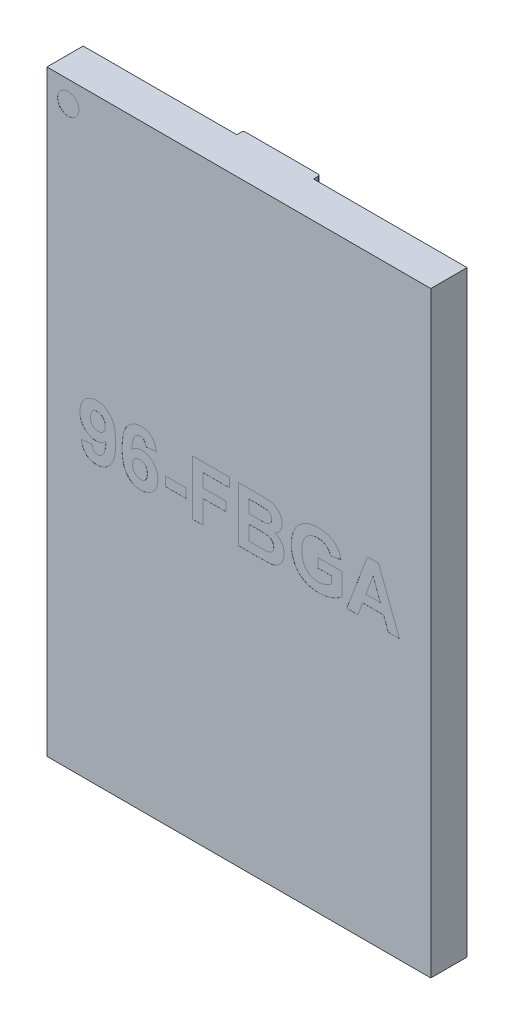
from build123d import *

# Parameters (mm, degrees)
SKETCH1_W           = 9
SKETCH1_H           = 14
BOSS_EXTRUDE1_DEPTH = 0.85
SKETCH2_W           = 1.8
SKETCH2_H           = 14
BOSS_EXTRUDE2_DEPTH = 0.155
SKETCH3_R           = 0.225
BOSS_EXTRUDE3_DEPTH = 0.25
FILLET1_R           = 0.05
FILLET3_R           = 0.225
SKETCH4_R           = 0.25
CUT_EXTRUDE1_DEPTH  = 0.001
SKETCH6_W           = 0.477443858
SKETCH6_H           = 0.214026557
CUT_EXTRUDE2_DEPTH  = 0.001


with BuildPart() as part:
    # Sketch1 → Boss-Extrude1 (new body)
    with BuildSketch(Plane.XY):
        Rectangle(SKETCH1_W, SKETCH1_H)
    extrude(amount=BOSS_EXTRUDE1_DEPTH)

    # Sketch2 → Boss-Extrude2 (add)
    with BuildSketch(Plane(origin=(0, 0, 0), x_dir=(-1, 0, 0), z_dir=(0, 0, -1))):
        Rectangle(SKETCH2_W, SKETCH2_H)
    extrude(amount=BOSS_EXTRUDE2_DEPTH)

    # Sketch3 → Boss-Extrude3 (add)
    with BuildSketch(Plane(origin=(0, 0, 0), x_dir=(-1, 0, 0), z_dir=(0, 0, -1))):
        with Locations((-3.2, 6)):
            Circle(SKETCH3_R)
        with Locations((-2.4, 6)):
            Circle(SKETCH3_R)
        with Locations((-1.6, 6)):
            Circle(SKETCH3_R)
        with Locations((-3.2, 5.2)):
            Circle(SKETCH3_R)
        with Locations((-2.4, 5.2)):
            Circle(SKETCH3_R)
        with Locations((-1.6, 5.2)):
            Circle(SKETCH3_R)
        with Locations((-3.2, 4.4)):
            Circle(SKETCH3_R)
        with Locations((-2.4, 4.4)):
            Circle(SKETCH3_R)
        with Locations((-1.6, 4.4)):
            Circle(SKETCH3_R)
        with Locations((-3.2, 3.6)):
            Circle(SKETCH3_R)
        with Locations((-2.4, 3.6)):
            Circle(SKETCH3_R)
        with Locations((-1.6, 3.6)):
            Circle(SKETCH3_R)
        with Locations((-3.2, 2.8)):
            Circle(SKETCH3_R)
        with Locations((-2.4, 2.8)):
            Circle(SKETCH3_R)
        with Locations((-1.6, 2.8)):
            Circle(SKETCH3_R)
        with Locations((-3.2, 2)):
            Circle(SKETCH3_R)
        with Locations((-2.4, 2)):
            Circle(SKETCH3_R)
        with Locations((-1.6, 2)):
            Circle(SKETCH3_R)
        with Locations((-3.2, 1.2)):
            Circle(SKETCH3_R)
        with Locations((-2.4, 1.2)):
            Circle(SKETCH3_R)
        with Locations((-1.6, 1.2)):
            Circle(SKETCH3_R)
        with Locations((-3.2, 0.4)):
            Circle(SKETCH3_R)
        with Locations((-2.4, 0.4)):
            Circle(SKETCH3_R)
        with Locations((-1.6, 0.4)):
            Circle(SKETCH3_R)
        with Locations((-3.2, -0.4)):
            Circle(SKETCH3_R)
        with Locations((-2.4, -0.4)):
            Circle(SKETCH3_R)
        with Locations((-1.6, -0.4)):
            Circle(SKETCH3_R)
        with Locations((-3.2, -1.2)):
            Circle(SKETCH3_R)
        with Locations((-2.4, -1.2)):
            Circle(SKETCH3_R)
        with Locations((-1.6, -1.2)):
            Circle(SKETCH3_R)
        with Locations((-3.2, -2)):
            Circle(SKETCH3_R)
        with Locations((-2.4, -2)):
            Circle(SKETCH3_R)
        with Locations((-1.6, -2)):
            Circle(SKETCH3_R)
        with Locations((-3.2, -2.8)):
            Circle(SKETCH3_R)
        with Locations((-2.4, -2.8)):
            Circle(SKETCH3_R)
        with Locations((-1.6, -2.8)):
            Circle(SKETCH3_R)
        with Locations((-3.2, -3.6)):
            Circle(SKETCH3_R)
        with Locations((-2.4, -3.6)):
            Circle(SKETCH3_R)
        with Locations((-1.6, -3.6)):
            Circle(SKETCH3_R)
        with Locations((-3.2, -4.4)):
            Circle(SKETCH3_R)
        with Locations((-2.4, -4.4)):
            Circle(SKETCH3_R)
        with Locations((-1.6, -4.4)):
            Circle(SKETCH3_R)
        with Locations((-3.2, -5.2)):
            Circle(SKETCH3_R)
        with Locations((-2.4, -5.2)):
            Circle(SKETCH3_R)
        with Locations((-1.6, -5.2)):
            Circle(SKETCH3_R)
        with Locations((-3.2, -6)):
            Circle(SKETCH3_R)
        with Locations((-2.4, -6)):
            Circle(SKETCH3_R)
        with Locations((-1.6, -6)):
            Circle(SKETCH3_R)
        with Locations((1.6, -6)):
            Circle(SKETCH3_R)
        with Locations((2.4, -6)):
            Circle(SKETCH3_R)
        with Locations((3.2, -6)):
            Circle(SKETCH3_R)
        with Locations((1.6, -5.2)):
            Circle(SKETCH3_R)
        with Locations((2.4, -5.2)):
            Circle(SKETCH3_R)
        with Locations((3.2, -5.2)):
            Circle(SKETCH3_R)
        with Locations((1.6, -4.4)):
            Circle(SKETCH3_R)
        with Locations((2.4, -4.4)):
            Circle(SKETCH3_R)
        with Locations((3.2, -4.4)):
            Circle(SKETCH3_R)
        with Locations((1.6, -3.6)):
            Circle(SKETCH3_R)
        with Locations((2.4, -3.6)):
            Circle(SKETCH3_R)
        with Locations((3.2, -3.6)):
            Circle(SKETCH3_R)
        with Locations((1.6, -2.8)):
            Circle(SKETCH3_R)
        with Locations((2.4, -2.8)):
            Circle(SKETCH3_R)
        with Locations((3.2, -2.8)):
            Circle(SKETCH3_R)
        with Locations((1.6, -2)):
            Circle(SKETCH3_R)
        with Locations((2.4, -2)):
            Circle(SKETCH3_R)
        with Locations((3.2, -2)):
            Circle(SKETCH3_R)
        with Locations((1.6, -1.2)):
            Circle(SKETCH3_R)
        with Locations((2.4, -1.2)):
            Circle(SKETCH3_R)
        with Locations((3.2, -1.2)):
            Circle(SKETCH3_R)
        with Locations((1.6, -0.4)):
            Circle(SKETCH3_R)
        with Locations((2.4, -0.4)):
            Circle(SKETCH3_R)
        with Locations((3.2, -0.4)):
            Circle(SKETCH3_R)
        with Locations((1.6, 0.4)):
            Circle(SKETCH3_R)
        with Locations((2.4, 0.4)):
            Circle(SKETCH3_R)
        with Locations((3.2, 0.4)):
            Circle(SKETCH3_R)
        with Locations((1.6, 1.2)):
            Circle(SKETCH3_R)
        with Locations((2.4, 1.2)):
            Circle(SKETCH3_R)
        with Locations((3.2, 1.2)):
            Circle(SKETCH3_R)
        with Locations((1.6, 2)):
            Circle(SKETCH3_R)
        with Locations((2.4, 2)):
            Circle(SKETCH3_R)
        with Locations((3.2, 2)):
            Circle(SKETCH3_R)
        with Locations((1.6, 2.8)):
            Circle(SKETCH3_R)
        with Locations((2.4, 2.8)):
            Circle(SKETCH3_R)
        with Locations((3.2, 2.8)):
            Circle(SKETCH3_R)
        with Locations((1.6, 3.6)):
            Circle(SKETCH3_R)
        with Locations((2.4, 3.6)):
            Circle(SKETCH3_R)
        with Locations((3.2, 3.6)):
            Circle(SKETCH3_R)
        with Locations((1.6, 4.4)):
            Circle(SKETCH3_R)
        with Locations((2.4, 4.4)):
            Circle(SKETCH3_R)
        with Locations((3.2, 4.4)):
            Circle(SKETCH3_R)
        with Locations((1.6, 5.2)):
            Circle(SKETCH3_R)
        with Locations((2.4, 5.2)):
            Circle(SKETCH3_R)
        with Locations((3.2, 5.2)):
            Circle(SKETCH3_R)
        with Locations((1.6, 6)):
            Circle(SKETCH3_R)
        with Locations((2.4, 6)):
            Circle(SKETCH3_R)
        with Locations((3.2, 6)):
            Circle(SKETCH3_R)
    extrude(amount=BOSS_EXTRUDE3_DEPTH)

    # Fillet1
    fillet1_edges = [part.edges().sort_by_distance(p)[0] for p in [
        (-0.9, 0, -0.155),
        (0.9, 0, -0.155),
    ]]
    fillet(fillet1_edges, radius=FILLET1_R)

    # Fillet3
    fillet3_edges = [part.edges().sort_by_distance(p)[0] for p in [
        (2.625, 0.4, -0.25),
        (1.825, 0.4, -0.25),
        (3.425, -0.4, -0.25),
        (2.625, -0.4, -0.25),
        (1.825, -0.4, -0.25),
        (3.425, -1.2, -0.25),
        (2.625, -1.2, -0.25),
        (1.825, -1.2, -0.25),
        (3.425, -2, -0.25),
        (2.625, -2, -0.25),
        (1.825, -2, -0.25),
        (3.425, -2.8, -0.25),
        (2.625, -2.8, -0.25),
        (1.825, -2.8, -0.25),
        (3.425, -3.6, -0.25),
        (2.625, -3.6, -0.25),
        (1.825, -3.6, -0.25),
        (3.425, -4.4, -0.25),
        (2.625, -4.4, -0.25),
        (1.825, -4.4, -0.25),
        (3.425, -5.2, -0.25),
        (2.625, -5.2, -0.25),
        (1.825, -5.2, -0.25),
        (3.425, -6, -0.25),
        (2.625, -6, -0.25),
        (1.825, -6, -0.25),
        (-2.175, -6, -0.25),
        (-2.975, -6, -0.25),
        (-1.375, -5.2, -0.25),
        (-2.175, -5.2, -0.25),
        (-2.975, -5.2, -0.25),
        (-1.375, -4.4, -0.25),
        (-2.175, -4.4, -0.25),
        (-2.975, -4.4, -0.25),
        (-1.375, -3.6, -0.25),
        (-2.175, -3.6, -0.25),
        (-2.975, -3.6, -0.25),
        (-1.375, -2.8, -0.25),
        (-2.175, -2.8, -0.25),
        (-2.975, -2.8, -0.25),
        (-1.375, -2, -0.25),
        (-2.175, -2, -0.25),
        (-2.975, -2, -0.25),
        (-1.375, -1.2, -0.25),
        (-2.175, -1.2, -0.25),
        (-2.975, -1.2, -0.25),
        (-1.375, -0.4, -0.25),
        (-2.175, -0.4, -0.25),
        (-2.975, -0.4, -0.25),
        (-1.375, 0.4, -0.25),
        (-2.175, 0.4, -0.25),
        (-2.975, 0.4, -0.25),
        (-1.375, 1.2, -0.25),
        (-2.175, 1.2, -0.25),
        (-2.975, 1.2, -0.25),
        (-1.375, 2, -0.25),
        (-2.175, 2, -0.25),
        (-2.975, 2, -0.25),
        (-1.375, 2.8, -0.25),
        (-2.175, 2.8, -0.25),
        (-2.975, 2.8, -0.25),
        (3.425, 6, -0.25),
        (-1.375, 3.6, -0.25),
        (-2.175, 3.6, -0.25),
        (-2.975, 3.6, -0.25),
        (-1.375, 4.4, -0.25),
        (-2.175, 4.4, -0.25),
        (-2.975, 4.4, -0.25),
        (-1.375, 5.2, -0.25),
        (-2.175, 5.2, -0.25),
        (-2.975, 5.2, -0.25),
        (-1.375, 6, -0.25),
        (-1.375, -6, -0.25),
        (-2.175, 6, -0.25),
        (-2.975, 6, -0.25),
        (2.625, 6, -0.25),
        (1.825, 6, -0.25),
        (3.425, 5.2, -0.25),
        (2.625, 5.2, -0.25),
        (1.825, 5.2, -0.25),
        (3.425, 4.4, -0.25),
        (2.625, 4.4, -0.25),
        (1.825, 4.4, -0.25),
        (3.425, 3.6, -0.25),
        (2.625, 3.6, -0.25),
        (1.825, 3.6, -0.25),
        (3.425, 2.8, -0.25),
        (2.625, 2.8, -0.25),
        (1.825, 2.8, -0.25),
        (3.425, 2, -0.25),
        (2.625, 2, -0.25),
        (1.825, 2, -0.25),
        (3.425, 1.2, -0.25),
        (2.625, 1.2, -0.25),
        (1.825, 1.2, -0.25),
        (3.425, 0.4, -0.25),
    ]]
    fillet(fillet3_edges, radius=FILLET3_R)

    # Sketch4 → Cut-Extrude1 (cut)
    with BuildSketch(Plane.XY.offset(0.85)):
        with Locations((-4, 6.5)):
            Circle(SKETCH4_R)
    extrude(amount=-CUT_EXTRUDE1_DEPTH, mode=Mode.SUBTRACT)

    # Sketch6 → Cut-Extrude2 (cut)
    with BuildSketch(Plane.XY.offset(0.85)):
        with BuildLine():
            Line((-3.6941683, -0.158633201), (-3.44721458, -0.131365395))
            add(Edge.make_bspline(
                [(-3.44721458, -0.131365395), (-3.445597513, -0.1431888), (-3.442540925, -0.165537465), (-3.432767179, -0.196204692), (-3.420517221, -0.222528967), (-3.403870298, -0.243712827), (-3.384004018, -0.259882053), (-3.361250879, -0.271549569), (-3.33552008, -0.27827039), (-3.317432242, -0.279104684), (-3.308045869, -0.279537626)],
                knots=[0, 0, 0, 0, 3.5736e-05, 6.7548e-05, 9.6194e-05, 0.000122389, 0.00014762, 0.00017247, 0.000198552, 0.000226687, 0.000226687, 0.000226687, 0.000226687], degree=3))
            add(Edge.make_bspline(
                [(-3.308045869, -0.279537626), (-3.301935615, -0.279396005), (-3.289860004, -0.279116119), (-3.27219485, -0.27517022), (-3.255100449, -0.269638338), (-3.238752999, -0.261541827), (-3.223308781, -0.25112172), (-3.208384828, -0.238613229), (-3.194438911, -0.223615351), (-3.180586529, -0.20640051), (-3.168047894, -0.185252833), (-3.15698184, -0.159602922), (-3.146649755, -0.129457889), (-3.138162522, -0.094442838), (-3.130523208, -0.054859542), (-3.12387741, -0.010581324), (-3.118485576, 0.038418872), (-3.116102459, 0.072703847), (-3.114856032, 0.09063571)],
                knots=[0, 0, 0, 0, 1.8293e-05, 3.6153e-05, 5.4049e-05, 7.2111e-05, 9.0661e-05, 0.000109831, 0.000130392, 0.000152007, 0.000176007, 0.000203876, 0.000235684, 0.000271496, 0.000311856, 0.000356605, 0.000405778, 0.0004597, 0.0004597, 0.0004597, 0.0004597], degree=3))
            add(Edge.make_bspline(
                [(-3.114856032, 0.09063571), (-3.122756333, 0.082156214), (-3.138332922, 0.065437657), (-3.164131316, 0.043503573), (-3.191599956, 0.025062744), (-3.220598314, 0.010198787), (-3.250823868, -0.00194512), (-3.282773553, -0.009933163), (-3.316002507, -0.015413754), (-3.338720564, -0.01588268), (-3.350233796, -0.016120325)],
                knots=[0, 0, 0, 0, 3.4747e-05, 6.8509e-05, 0.000101328, 0.000133773, 0.000166113, 0.000198808, 0.000232389, 0.000266894, 0.000266894, 0.000266894, 0.000266894], degree=3))
            add(Edge.make_bspline(
                [(-3.350233796, -0.016120325), (-3.362854981, -0.015758359), (-3.387774455, -0.015043687), (-3.424434601, -0.009853301), (-3.459756763, -0.001002383), (-3.493797335, 0.011271441), (-3.52638423, 0.027539759), (-3.55793297, 0.046719733), (-3.587766552, 0.069935896), (-3.616320276, 0.095877054), (-3.641998326, 0.125081247), (-3.664930957, 0.156396132), (-3.684336591, 0.189993944), (-3.699988924, 0.225838973), (-3.712094268, 0.263703059), (-3.720895314, 0.303554404), (-3.726037676, 0.345600662), (-3.726738049, 0.374361129), (-3.727095462, 0.389038121)],
                knots=[0, 0, 0, 0, 3.7858e-05, 7.4747e-05, 0.000110809, 0.00014694, 0.000183064, 0.000219904, 0.000257515, 0.000296294, 0.000335474, 0.000373962, 0.00041257, 0.000451618, 0.000491074, 0.000531643, 0.000573888, 0.000617914, 0.000617914, 0.000617914, 0.000617914], degree=3))
            add(Edge.make_bspline(
                [(-3.727095462, 0.389038121), (-3.726770225, 0.404319282), (-3.726132249, 0.434294384), (-3.720535282, 0.477995335), (-3.711987508, 0.519594797), (-3.699224156, 0.558724125), (-3.683342012, 0.595803573), (-3.663601839, 0.630368136), (-3.640657581, 0.662898573), (-3.613846204, 0.692427562), (-3.584701766, 0.719458481), (-3.553261909, 0.742981411), (-3.519709029, 0.762639902), (-3.484340384, 0.778976812), (-3.446890652, 0.791558627), (-3.407599179, 0.800524673), (-3.36642776, 0.806084092), (-3.338332686, 0.806729414), (-3.323994964, 0.80705874)],
                knots=[0, 0, 0, 0, 4.5825e-05, 8.9889e-05, 0.000131966, 0.000173049, 0.000213144, 0.000252772, 0.000292246, 0.000332323, 0.000372192, 0.000411345, 0.00044986, 0.00048865, 0.000528023, 0.000568147, 0.000609404, 0.000652401, 0.000652401, 0.000652401, 0.000652401], degree=3))
            add(Edge.make_bspline(
                [(-3.323994964, 0.80705874), (-3.308364122, 0.806626847), (-3.277713883, 0.805779956), (-3.232792546, 0.798727765), (-3.190169369, 0.786729218), (-3.149420829, 0.770639367), (-3.111134267, 0.749203756), (-3.074811587, 0.723332925), (-3.040938092, 0.692498706), (-3.008920722, 0.657311722), (-2.979790285, 0.61665342), (-2.954988585, 0.569662966), (-2.933892013, 0.516785295), (-2.916863592, 0.457906851), (-2.903557877, 0.39304273), (-2.894374433, 0.322194179), (-2.888229413, 0.245347164), (-2.887718047, 0.192088424), (-2.887452815, 0.164464582)],
                knots=[0, 0, 0, 0, 4.6876e-05, 9.1917e-05, 0.000135981, 0.000179499, 0.000223024, 0.000267282, 0.000312999, 0.00036017, 0.000409781, 0.000462607, 0.000519165, 0.000580297, 0.000646236, 0.000717615, 0.000794502, 0.000877354, 0.000877354, 0.000877354, 0.000877354], degree=3))
            add(Edge.make_bspline(
                [(-2.887452815, 0.164464582), (-2.887836168, 0.136413376), (-2.888576821, 0.082217277), (-2.894552876, 0.003977961), (-2.90401188, -0.068263899), (-2.917919177, -0.134379226), (-2.935371885, -0.194605751), (-2.957317665, -0.248714058), (-2.982877246, -0.296983202), (-3.012798123, -0.338968736), (-3.045691993, -0.37545889), (-3.081046621, -0.407071789), (-3.118912686, -0.433712107), (-3.158961589, -0.455933615), (-3.201792147, -0.472574378), (-3.246811671, -0.48463028), (-3.294141264, -0.492439952), (-3.326536252, -0.493184883), (-3.34303098, -0.493564184)],
                knots=[0, 0, 0, 0, 8.4144e-05, 0.000162569, 0.000235258, 0.000302561, 0.000365072, 0.000423112, 0.000477436, 0.000528542, 0.000577358, 0.000624548, 0.000670511, 0.000715986, 0.000761606, 0.00080797, 0.000855633, 0.000905078, 0.000905078, 0.000905078, 0.000905078], degree=3))
            add(Edge.make_bspline(
                [(-3.34303098, -0.493564184), (-3.354873972, -0.493320459), (-3.378110475, -0.492842261), (-3.412130338, -0.488995122), (-3.444410923, -0.482310039), (-3.474844784, -0.472973975), (-3.503669445, -0.461493508), (-3.530640187, -0.446928618), (-3.555764037, -0.429612222), (-3.579468797, -0.410076536), (-3.600802192, -0.387431419), (-3.620426377, -0.362429543), (-3.638030566, -0.334820732), (-3.65302353, -0.304367675), (-3.666863515, -0.271776844), (-3.678012205, -0.236325889), (-3.687310436, -0.198414841), (-3.691841975, -0.172127932), (-3.6941683, -0.158633201)],
                knots=[0, 0, 0, 0, 3.5523e-05, 6.9698e-05, 0.000102541, 0.000134277, 0.000165088, 0.000195474, 0.000226012, 0.000256511, 0.000287443, 0.000319142, 0.000351755, 0.000385463, 0.000420864, 0.000457879, 0.000496811, 0.000537882, 0.000537882, 0.000537882, 0.000537882], degree=3))
        make_face()
        with BuildLine():
            add(Edge.make_bspline(
                [(-3.134406535, 0.382864278), (-3.134497495, 0.391020365), (-3.134674275, 0.406871721), (-3.1376806, 0.429827216), (-3.142042552, 0.451323728), (-3.147819587, 0.471599728), (-3.15588534, 0.490319993), (-3.165452178, 0.507779308), (-3.176756522, 0.523837673), (-3.194158853, 0.542597341), (-3.21778101, 0.562790273), (-3.249425269, 0.580329997), (-3.283413281, 0.591266094), (-3.306936063, 0.592438415), (-3.318850095, 0.593032183)],
                knots=[0, 0, 0, 0, 2.445e-05, 4.7519e-05, 6.9314e-05, 9.0233e-05, 0.000110635, 0.000130323, 0.000149881, 0.000169365, 0.000206979, 0.000242559, 0.000277302, 0.000312958, 0.000312958, 0.000312958, 0.000312958], degree=3))
            add(Edge.make_bspline(
                [(-3.318850095, 0.593032183), (-3.329971123, 0.592527932), (-3.351616997, 0.591546462), (-3.382596974, 0.582725434), (-3.410661651, 0.56840864), (-3.43110388, 0.551706173), (-3.445671966, 0.535775457), (-3.454802591, 0.521505128), (-3.462577177, 0.505598797), (-3.469013942, 0.487920845), (-3.474092959, 0.468461693), (-3.477694027, 0.44711756), (-3.479654279, 0.424060328), (-3.47997598, 0.40807769), (-3.480141743, 0.399842346)],
                knots=[0, 0, 0, 0, 3.3305e-05, 6.4824e-05, 9.5773e-05, 0.00012723, 0.000143445, 0.000160354, 0.000177841, 0.000196478, 0.000216695, 0.000238094, 0.000261337, 0.000286044, 0.000286044, 0.000286044, 0.000286044], degree=3))
            add(Edge.make_bspline(
                [(-3.480141743, 0.399842346), (-3.480009081, 0.391432301), (-3.47975269, 0.375178503), (-3.477347615, 0.351631268), (-3.473739598, 0.329782777), (-3.467878746, 0.309803619), (-3.460992689, 0.291409379), (-3.452677328, 0.274544142), (-3.442117667, 0.259830914), (-3.426863739, 0.242379406), (-3.404546531, 0.224614937), (-3.374286972, 0.209125166), (-3.340858939, 0.199549084), (-3.317456148, 0.198462556), (-3.305473435, 0.197906232)],
                knots=[0, 0, 0, 0, 2.5222e-05, 4.8745e-05, 7.0949e-05, 9.1549e-05, 0.000111089, 0.000129842, 0.000147755, 0.000165251, 0.000199279, 0.000232528, 0.000266733, 0.000302623, 0.000302623, 0.000302623, 0.000302623], degree=3))
            add(Edge.make_bspline(
                [(-3.305473435, 0.197906232), (-3.293828551, 0.198362513), (-3.271106428, 0.199252834), (-3.238779049, 0.208762167), (-3.209102401, 0.223348421), (-3.187390575, 0.240563319), (-3.171869398, 0.256868461), (-3.161879658, 0.2708709), (-3.153267753, 0.286196303), (-3.146390343, 0.302980794), (-3.140981426, 0.321078607), (-3.137172708, 0.340460171), (-3.134807299, 0.361197135), (-3.134543057, 0.375483284), (-3.134406535, 0.382864278)],
                knots=[0, 0, 0, 0, 3.4843e-05, 6.7987e-05, 0.000100199, 0.000133546, 0.000150471, 0.000167607, 0.000184997, 0.000203103, 0.000221903, 0.000241578, 0.000262287, 0.000284424, 0.000284424, 0.000284424, 0.000284424], degree=3))
        make_face(mode=Mode.SUBTRACT)
        with BuildLine():
            Line((-1.932565099, 0.471870514), (-2.179518819, 0.444859951))
            add(Edge.make_bspline(
                [(-2.179518819, 0.444859951), (-2.181173328, 0.456754335), (-2.184286813, 0.479137393), (-2.193508795, 0.510025997), (-2.206346836, 0.536011197), (-2.222825707, 0.557129325), (-2.242453778, 0.573382713), (-2.264818906, 0.584931736), (-2.289906875, 0.591787519), (-2.307496281, 0.592606781), (-2.316629582, 0.593032183)],
                knots=[0, 0, 0, 0, 3.5989e-05, 6.7725e-05, 9.6256e-05, 0.000122451, 0.000147483, 0.000172104, 0.000197441, 0.000224807, 0.000224807, 0.000224807, 0.000224807], degree=3))
            add(Edge.make_bspline(
                [(-2.316629582, 0.593032183), (-2.322823127, 0.592880738), (-2.335147968, 0.592579368), (-2.353100596, 0.588753179), (-2.370409089, 0.583075089), (-2.386932185, 0.575033273), (-2.402752326, 0.564656799), (-2.417629007, 0.55182164), (-2.432246171, 0.537204368), (-2.445743465, 0.519553327), (-2.458692548, 0.498653255), (-2.469842232, 0.473067625), (-2.479779953, 0.442820208), (-2.488288768, 0.407762859), (-2.496010431, 0.3681181), (-2.502340003, 0.323725445), (-2.507404888, 0.274545009), (-2.509834711, 0.240102408), (-2.511105636, 0.222087117)],
                knots=[0, 0, 0, 0, 1.855e-05, 3.6914e-05, 5.481e-05, 7.3103e-05, 9.1868e-05, 0.0001114, 0.000131955, 0.000153773, 0.000177906, 0.00020554, 0.000237265, 0.000273327, 0.000313687, 0.000358398, 0.0004078, 0.000461978, 0.000461978, 0.000461978, 0.000461978], degree=3))
            add(Edge.make_bspline(
                [(-2.511105636, 0.222087117), (-2.503212962, 0.230659601), (-2.487736257, 0.247469342), (-2.46205552, 0.269385381), (-2.435151126, 0.288122131), (-2.406730318, 0.303493974), (-2.376637965, 0.314933255), (-2.345419165, 0.323618882), (-2.312665264, 0.328484143), (-2.290405851, 0.329233389), (-2.279072037, 0.329614882)],
                knots=[0, 0, 0, 0, 3.4932e-05, 6.8498e-05, 0.000101037, 0.000133147, 0.000165154, 0.000197418, 0.000230197, 0.000264201, 0.000264201, 0.000264201, 0.000264201], degree=3))
            add(Edge.make_bspline(
                [(-2.279072037, 0.329614882), (-2.266280883, 0.329246498), (-2.241022897, 0.328519069), (-2.203812021, 0.323417033), (-2.16810574, 0.314242656), (-2.133742528, 0.301832039), (-2.100552545, 0.286203977), (-2.069170682, 0.266421183), (-2.039104325, 0.243355335), (-2.010766976, 0.217002883), (-1.984731767, 0.187991047), (-1.961745252, 0.15665597), (-1.942828106, 0.122901959), (-1.926656211, 0.087484718), (-1.914623705, 0.04970507), (-1.905889377, 0.010106665), (-1.900675599, -0.031673978), (-1.899989266, -0.060179853), (-1.899637937, -0.074771834)],
                knots=[0, 0, 0, 0, 3.8372e-05, 7.577e-05, 0.000112394, 0.000148767, 0.000185242, 0.000222217, 0.000259829, 0.000298782, 0.000338133, 0.00037662, 0.000415101, 0.000454018, 0.000493229, 0.000533799, 0.000575533, 0.000619302, 0.000619302, 0.000619302, 0.000619302], degree=3))
            add(Edge.make_bspline(
                [(-1.899637937, -0.074771834), (-1.899994394, -0.090219446), (-1.900689571, -0.120345991), (-1.90580656, -0.164467029), (-1.914845338, -0.206112322), (-1.927194259, -0.245615991), (-1.943167229, -0.282665013), (-1.962517187, -0.317564711), (-1.98589895, -0.349718677), (-2.012251399, -0.379559428), (-2.041629166, -0.406188435), (-2.072937522, -0.429768735), (-2.106523724, -0.449370349), (-2.141891324, -0.465868464), (-2.179647788, -0.477975915), (-2.219127476, -0.487055895), (-2.260651409, -0.492593871), (-2.289001679, -0.493235715), (-2.303510166, -0.493564184)],
                knots=[0, 0, 0, 0, 4.6339e-05, 9.0372e-05, 0.000133007, 0.000174011, 0.000214342, 0.000253844, 0.000293467, 0.000333373, 0.000373069, 0.000412221, 0.000450737, 0.000489527, 0.000529062, 0.000569437, 0.000610949, 0.00065446, 0.00065446, 0.00065446, 0.00065446], degree=3))
            add(Edge.make_bspline(
                [(-2.303510166, -0.493564184), (-2.319055729, -0.493129262), (-2.349621071, -0.492274128), (-2.394365337, -0.485236813), (-2.436904375, -0.473330789), (-2.477232901, -0.456703518), (-2.515686112, -0.435788986), (-2.551906942, -0.409809325), (-2.585799408, -0.379012281), (-2.617811791, -0.343814918), (-2.646942201, -0.303159184), (-2.671749908, -0.256169704), (-2.692789328, -0.203361109), (-2.709918499, -0.144597963), (-2.723140982, -0.079884929), (-2.732367331, -0.009216579), (-2.738495555, 0.067290218), (-2.739012718, 0.120291594), (-2.739280584, 0.147743757)],
                knots=[0, 0, 0, 0, 4.6619e-05, 9.166e-05, 0.000135476, 0.000178852, 0.000222253, 0.000266511, 0.000312229, 0.0003594, 0.000409011, 0.000461836, 0.000518395, 0.00057928, 0.000645219, 0.000716343, 0.000792973, 0.000875311, 0.000875311, 0.000875311, 0.000875311], degree=3))
            add(Edge.make_bspline(
                [(-2.739280584, 0.147743757), (-2.738896636, 0.175880494), (-2.738154756, 0.23024745), (-2.732184923, 0.308745891), (-2.722702368, 0.381235865), (-2.708888651, 0.447553902), (-2.69121984, 0.507837608), (-2.669799261, 0.562208131), (-2.644088762, 0.610468634), (-2.614196284, 0.65246217), (-2.581305943, 0.688965606), (-2.545965127, 0.720474268), (-2.508308756, 0.747292836), (-2.468337732, 0.769353587), (-2.425723927, 0.786077719), (-2.380871545, 0.798154634), (-2.33370525, 0.805916275), (-2.301397084, 0.806673942), (-2.284988637, 0.80705874)],
                knots=[0, 0, 0, 0, 8.4401e-05, 0.000163083, 0.000236026, 0.000303582, 0.000366092, 0.000424275, 0.000478599, 0.000529705, 0.00057852, 0.000625711, 0.000671464, 0.000716939, 0.000762319, 0.000808436, 0.000856099, 0.000905287, 0.000905287, 0.000905287, 0.000905287], degree=3))
            add(Edge.make_bspline(
                [(-2.284988637, 0.80705874), (-2.273398756, 0.806850232), (-2.250742022, 0.806442625), (-2.217535316, 0.802114182), (-2.185856427, 0.795495291), (-2.155622328, 0.78633321), (-2.127045886, 0.77406341), (-2.100013624, 0.759115953), (-2.074434666, 0.741531321), (-2.050442101, 0.72142273), (-2.028229029, 0.698729321), (-2.008171138, 0.67339975), (-1.990135597, 0.645739714), (-1.974043471, 0.615772168), (-1.960545662, 0.583210097), (-1.948942067, 0.548309562), (-1.939398918, 0.510995584), (-1.934877772, 0.485111057), (-1.932565099, 0.471870514)],
                knots=[0, 0, 0, 0, 3.4752e-05, 6.7935e-05, 0.000100275, 0.000131765, 0.000162537, 0.000193394, 0.00022429, 0.000255514, 0.000287167, 0.000319387, 0.000352279, 0.000386114, 0.000421277, 0.000457884, 0.000496379, 0.000536691, 0.000536691, 0.000536691, 0.000536691], degree=3))
        make_face()
        with BuildLine():
            add(Edge.make_bspline(
                [(-2.492326864, -0.069112478), (-2.492233101, -0.07726842), (-2.492049892, -0.093204662), (-2.489045611, -0.116329312), (-2.484727216, -0.138008256), (-2.478910577, -0.158361881), (-2.470848321, -0.177082145), (-2.461283163, -0.194544529), (-2.449968905, -0.210590805), (-2.432608545, -0.229417772), (-2.408619841, -0.249191791), (-2.377138186, -0.266800486), (-2.343406441, -0.277746296), (-2.320139404, -0.278936829), (-2.308397791, -0.279537626)],
                knots=[0, 0, 0, 0, 2.445e-05, 4.7775e-05, 6.9821e-05, 9.074e-05, 0.000111142, 0.000130831, 0.000150388, 0.000169872, 0.00020752, 0.000243099, 0.000277597, 0.000312741, 0.000312741, 0.000312741, 0.000312741], degree=3))
            add(Edge.make_bspline(
                [(-2.308397791, -0.279537626), (-2.297274881, -0.279038413), (-2.275625343, -0.278066749), (-2.244709294, -0.269186454), (-2.216626734, -0.25518131), (-2.19604004, -0.238739131), (-2.181685384, -0.222747096), (-2.172039384, -0.208722534), (-2.16418753, -0.192724), (-2.157768238, -0.175014986), (-2.152597546, -0.155663989), (-2.149067272, -0.134476577), (-2.147064855, -0.111510776), (-2.146753137, -0.095612596), (-2.146591656, -0.087376763)],
                knots=[0, 0, 0, 0, 3.3305e-05, 6.4824e-05, 9.5656e-05, 0.000126952, 0.000143166, 0.000160006, 0.000177837, 0.000196475, 0.000216442, 0.000237841, 0.000260828, 0.000285536, 0.000285536, 0.000285536, 0.000285536], degree=3))
            add(Edge.make_bspline(
                [(-2.146591656, -0.087376763), (-2.146729398, -0.078882251), (-2.146995694, -0.062459807), (-2.149325995, -0.038723909), (-2.153138285, -0.016781029), (-2.158468163, 0.003523884), (-2.165682724, 0.021919229), (-2.174194126, 0.038776041), (-2.184527717, 0.053637212), (-2.199885143, 0.071115864), (-2.222215434, 0.088727974), (-2.252052912, 0.10476981), (-2.285497558, 0.113864031), (-2.308773568, 0.115002671), (-2.320745477, 0.115588325)],
                knots=[0, 0, 0, 0, 2.5479e-05, 4.9258e-05, 7.1462e-05, 9.2241e-05, 0.000112114, 0.000130637, 0.000148762, 0.000166258, 0.000200286, 0.000233426, 0.000267313, 0.000303203, 0.000303203, 0.000303203, 0.000303203], degree=3))
            add(Edge.make_bspline(
                [(-2.320745477, 0.115588325), (-2.332385212, 0.115114195), (-2.354991402, 0.11419336), (-2.38747917, 0.104946205), (-2.417205815, 0.090232386), (-2.439101283, 0.072946605), (-2.454533609, 0.056655307), (-2.464641113, 0.042784407), (-2.473439199, 0.027682546), (-2.480387259, 0.010959229), (-2.485744106, -0.007071716), (-2.489586227, -0.026533504), (-2.491911227, -0.047361593), (-2.492185831, -0.061731992), (-2.492326864, -0.069112478)],
                knots=[0, 0, 0, 0, 3.4843e-05, 6.767e-05, 0.000100458, 0.000133804, 0.00015073, 0.000167657, 0.000185174, 0.000203043, 0.000221843, 0.000241518, 0.000262483, 0.000284619, 0.000284619, 0.000284619, 0.000284619], degree=3))
        make_face(mode=Mode.SUBTRACT)
        with Locations((-1.479816613, -0.024352116)):
            Rectangle(SKETCH6_W, SKETCH6_H)
        Polygon((-1.092922452, -0.477100602), (-1.092922452, 0.80705874), (-0.220352643, 0.80705874), (-0.220352643, 0.593032183), (-0.845968733, 0.593032183), (-0.845968733, 0.280224138), (-0.302670549, 0.280224138), (-0.302670549, 0.066197581), (-0.845968733, 0.066197581), (-0.845968733, -0.477100602), align=None)
        with BuildLine():
            Line((-0.006326086, 0.80705874), (0.510990508, 0.80705874))
            add(Edge.make_bspline(
                [(0.510990508, 0.80705874), (0.523423833, 0.806984762), (0.547434008, 0.806841903), (0.582255263, 0.806443769), (0.614576264, 0.805274546), (0.644447339, 0.804270541), (0.671769143, 0.801922591), (0.696756405, 0.800077893), (0.719330455, 0.79754007), (0.745923274, 0.793433118), (0.776846025, 0.787045044), (0.811772515, 0.775228835), (0.844879403, 0.760465638), (0.875669061, 0.741696491), (0.904243765, 0.719744795), (0.930822055, 0.694785396), (0.954177935, 0.665809707), (0.975209535, 0.634184984), (0.99296171, 0.599884665), (1.00518628, 0.562984352), (1.012987657, 0.524160617), (1.013933229, 0.497547362), (1.014415956, 0.483960957)],
                knots=[0, 0, 0, 0, 3.7301e-05, 7.2033e-05, 0.000104462, 0.00013433, 0.000161675, 0.000186713, 0.000209496, 0.000229797, 0.000267437, 0.000304043, 0.000340193, 0.000375972, 0.000411937, 0.000448146, 0.000485069, 0.000523311, 0.000561966, 0.000600525, 0.000639574, 0.000680299, 0.000680299, 0.000680299, 0.000680299], degree=3))
            add(Edge.make_bspline(
                [(1.014415956, 0.483960957), (1.0139153, 0.469165706), (1.012928118, 0.439992754), (1.003739638, 0.39721352), (0.989103457, 0.356283718), (0.968439272, 0.31786733), (0.943129845, 0.28261346), (0.913193022, 0.251656285), (0.879068668, 0.225184031), (0.853445292, 0.212011353), (0.840519378, 0.205366292)],
                knots=[0, 0, 0, 0, 4.4336e-05, 8.7421e-05, 0.00013063, 0.000174361, 0.000217842, 0.000260413, 0.000303168, 0.000346694, 0.000346694, 0.000346694, 0.000346694], degree=3))
            add(Edge.make_bspline(
                [(0.840519378, 0.205366292), (0.849225229, 0.202400993), (0.866438935, 0.196537833), (0.891077706, 0.185771397), (0.914162901, 0.173285597), (0.935682926, 0.159474153), (0.955801112, 0.144236096), (0.973929684, 0.127066171), (0.991108869, 0.108941221), (1.006190862, 0.088951428), (1.019842379, 0.068052873), (1.031430478, 0.04591845), (1.041464806, 0.023080551), (1.0498567, -0.000691961), (1.055838656, -0.025558526), (1.060631771, -0.05120589), (1.063083795, -0.077811807), (1.063563753, -0.095776107), (1.0638067, -0.104869318)],
                knots=[0, 0, 0, 0, 2.7583e-05, 5.4538e-05, 8.055e-05, 0.000106239, 0.000131192, 0.000156129, 0.000181066, 0.00020602, 0.000231136, 0.000255877, 0.000280874, 0.000305931, 0.000331386, 0.000357524, 0.000384144, 0.000411432, 0.000411432, 0.000411432, 0.000411432], degree=3))
            add(Edge.make_bspline(
                [(1.0638067, -0.104869318), (1.063289982, -0.119390553), (1.062258932, -0.14836599), (1.054554026, -0.191591163), (1.041541186, -0.234055063), (1.023919114, -0.275482214), (1.002030557, -0.31454466), (0.976297219, -0.350208603), (0.946273187, -0.381239668), (0.913024169, -0.408582556), (0.875557534, -0.431218569), (0.833905293, -0.448606202), (0.788330661, -0.461742218), (0.756223548, -0.466105888), (0.739679943, -0.468354325)],
                knots=[0, 0, 0, 0, 4.355e-05, 8.6899e-05, 0.000131251, 0.000176547, 0.000221696, 0.000265328, 0.000308084, 0.000350872, 0.000394151, 0.000438873, 0.000485939, 0.000535969, 0.000535969, 0.000535969, 0.000535969], degree=3))
            add(Edge.make_bspline(
                [(0.739679943, -0.468354325), (0.733336213, -0.468889452), (0.718773694, -0.47011788), (0.694076471, -0.471645148), (0.663710011, -0.472799593), (0.627700682, -0.474164578), (0.58593763, -0.475150137), (0.538515772, -0.475823141), (0.485354192, -0.476696567), (0.448051982, -0.476961262), (0.428415358, -0.477100602)],
                knots=[0, 0, 0, 0, 1.9098e-05, 4.3842e-05, 7.4224e-05, 0.000110261, 0.000151947, 0.000199543, 0.000252541, 0.000311452, 0.000311452, 0.000311452, 0.000311452], degree=3))
            Line((0.428415358, -0.477100602), (-0.006326086, -0.477100602))
            Line((-0.006326086, -0.477100602), (-0.006326086, 0.80705874))
        make_face()
        with BuildLine():
            Line((0.240627634, 0.593032183), (0.240627634, 0.29668772))
            Line((0.240627634, 0.29668772), (0.419411837, 0.29668772))
            add(Edge.make_bspline(
                [(0.419411837, 0.29668772), (0.432016879, 0.296659949), (0.456026803, 0.296607053), (0.490153695, 0.296961521), (0.520596182, 0.297127002), (0.547266744, 0.297612665), (0.570159902, 0.298414189), (0.589193172, 0.299214575), (0.604476537, 0.29982056), (0.613375686, 0.30068588), (0.617232057, 0.301060858)],
                knots=[0, 0, 0, 0, 3.7815e-05, 7.2029e-05, 0.000102385, 0.000129143, 0.000152051, 0.000171103, 0.0001863, 0.000197921, 0.000197921, 0.000197921, 0.000197921], degree=3))
            add(Edge.make_bspline(
                [(0.617232057, 0.301060858), (0.628353225, 0.302734341), (0.649727428, 0.305950672), (0.679637205, 0.315375279), (0.705579975, 0.329006232), (0.727843712, 0.34597317), (0.745516473, 0.366789616), (0.758485548, 0.390736063), (0.766073411, 0.417913135), (0.766987745, 0.437008439), (0.767462236, 0.446917899)],
                knots=[0, 0, 0, 0, 3.3708e-05, 6.4784e-05, 9.3551e-05, 0.000121234, 0.000148243, 0.00017483, 0.000202357, 0.000232051, 0.000232051, 0.000232051, 0.000232051], degree=3))
            add(Edge.make_bspline(
                [(0.767462236, 0.446917899), (0.767164381, 0.456486837), (0.766592573, 0.47485682), (0.759489396, 0.500866169), (0.748810303, 0.524224648), (0.733200315, 0.544358397), (0.713612189, 0.561361566), (0.689637346, 0.574643377), (0.661390912, 0.583782521), (0.641044831, 0.586979039), (0.630351473, 0.588659044)],
                knots=[0, 0, 0, 0, 2.8628e-05, 5.4959e-05, 8.0275e-05, 0.000105229, 0.000130759, 0.000157594, 0.000186879, 0.000219322, 0.000219322, 0.000219322, 0.000219322], degree=3))
            add(Edge.make_bspline(
                [(0.630351473, 0.588659044), (0.626151966, 0.589035159), (0.616223581, 0.589924361), (0.598967924, 0.590502407), (0.577019744, 0.591315969), (0.550267166, 0.592109964), (0.518709466, 0.592594743), (0.482436396, 0.59275813), (0.441449575, 0.593114146), (0.412552108, 0.593060512), (0.3972889, 0.593032183)],
                knots=[0, 0, 0, 0, 1.2647e-05, 2.9899e-05, 5.1779e-05, 7.8543e-05, 0.000110188, 0.000146461, 0.000187363, 0.000233152, 0.000233152, 0.000233152, 0.000233152], degree=3))
            Line((0.3972889, 0.593032183), (0.240627634, 0.593032183))
        make_face(mode=Mode.SUBTRACT)
        with BuildLine():
            Line((0.240627634, 0.082661162), (0.240627634, -0.263074045))
            Line((0.240627634, -0.263074045), (0.492726223, -0.263074045))
            add(Edge.make_bspline(
                [(0.492726223, -0.263074045), (0.504474256, -0.263132321), (0.526771188, -0.263242926), (0.558579168, -0.262502112), (0.586974164, -0.262257839), (0.612089078, -0.261039146), (0.633791935, -0.260117217), (0.652172035, -0.258967878), (0.667085868, -0.257140097), (0.675886882, -0.255721098), (0.679742217, -0.255099498)],
                knots=[0, 0, 0, 0, 3.5242e-05, 6.6887e-05, 9.5446e-05, 0.00012042, 0.00014231, 0.000160619, 0.000175648, 0.000187363, 0.000187363, 0.000187363, 0.000187363], degree=3))
            add(Edge.make_bspline(
                [(0.679742217, -0.255099498), (0.689532792, -0.253033753), (0.708555115, -0.249020171), (0.73491981, -0.237503168), (0.758681589, -0.222897518), (0.779261127, -0.204126198), (0.796176441, -0.181638673), (0.8083905, -0.155385411), (0.8157564, -0.125675295), (0.816476715, -0.104742408), (0.81685298, -0.09380785)],
                knots=[0, 0, 0, 0, 2.9948e-05, 5.8186e-05, 8.5808e-05, 0.000113304, 0.000141241, 0.000169665, 0.000199613, 0.000232364, 0.000232364, 0.000232364, 0.000232364], degree=3))
            add(Edge.make_bspline(
                [(0.81685298, -0.09380785), (0.816549324, -0.084430525), (0.815958294, -0.066178657), (0.810172894, -0.04003636), (0.800814065, -0.016133744), (0.787780727, 0.005366078), (0.771497165, 0.024733124), (0.751367408, 0.040940633), (0.728127135, 0.054444022), (0.70597231, 0.063339902), (0.684963794, 0.069047139), (0.664926079, 0.072791199), (0.640776537, 0.075754906), (0.612632246, 0.078261874), (0.580378996, 0.080266659), (0.54410347, 0.0818471), (0.503704439, 0.082508576), (0.475405254, 0.082608685), (0.460570791, 0.082661162)],
                knots=[0, 0, 0, 0, 2.8097e-05, 5.4688e-05, 7.9863e-05, 0.000104789, 0.000129789, 0.000155382, 0.000181898, 0.000210177, 0.000226715, 0.000247147, 0.000271269, 0.000299683, 0.000331904, 0.000368208, 0.000408603, 0.000453107, 0.000453107, 0.000453107, 0.000453107], degree=3))
            Line((0.460570791, 0.082661162), (0.240627634, 0.082661162))
        make_face(mode=Mode.SUBTRACT)
        with BuildLine():
            Line((1.854058603, 0.000343256), (1.854058603, 0.214369813))
            Line((1.854058603, 0.214369813), (2.413820367, 0.214369813))
            Line((2.413820367, 0.214369813), (2.413820367, -0.30140332))
            add(Edge.make_bspline(
                [(2.413820367, -0.30140332), (2.406775614, -0.307747393), (2.392374712, -0.320715962), (2.36887482, -0.338999286), (2.343017375, -0.356478291), (2.314855576, -0.373405843), (2.284638647, -0.390112594), (2.25212177, -0.406122235), (2.217222039, -0.421139829), (2.168364823, -0.441078598), (2.105017889, -0.461856839), (2.027793464, -0.480259971), (1.949910871, -0.491467205), (1.897825608, -0.492865646), (1.871808401, -0.493564184)],
                knots=[0, 0, 0, 0, 2.8434e-05, 5.8126e-05, 8.9234e-05, 0.000122013, 0.000156669, 0.000192793, 0.000230692, 0.000270627, 0.00035108, 0.000430385, 0.000508566, 0.000586594, 0.000586594, 0.000586594, 0.000586594], degree=3))
            add(Edge.make_bspline(
                [(1.871808401, -0.493564184), (1.855509072, -0.493319252), (1.823378245, -0.492836419), (1.775945823, -0.488950119), (1.730154341, -0.482300678), (1.685966483, -0.472884751), (1.643232677, -0.461534062), (1.60213105, -0.447054503), (1.562807528, -0.429672948), (1.524905838, -0.410304795), (1.489132558, -0.388058895), (1.455453132, -0.363723864), (1.424111324, -0.337088036), (1.395219495, -0.308097717), (1.368390739, -0.276952572), (1.343938088, -0.24350408), (1.322009416, -0.207713627), (1.302334043, -0.170030164), (1.284830021, -0.130785106), (1.270059693, -0.090287333), (1.257110522, -0.049124828), (1.246467719, -0.007153078), (1.2386511, 0.035764373), (1.232574621, 0.07942895), (1.229310962, 0.12411347), (1.228733962, 0.154170231), (1.228442513, 0.169352208)],
                knots=[0, 0, 0, 0, 4.8893e-05, 9.6383e-05, 0.000142658, 0.000187611, 0.000231855, 0.000275219, 0.000318186, 0.000360755, 0.000402803, 0.00044443, 0.000485307, 0.000526052, 0.000567096, 0.000608515, 0.000650209, 0.000692897, 0.000735967, 0.000779022, 0.000822144, 0.000865381, 0.000908822, 0.000952952, 0.00099758, 0.00104313, 0.00104313, 0.00104313, 0.00104313], degree=3))
            add(Edge.make_bspline(
                [(1.228442513, 0.169352208), (1.228678874, 0.18573839), (1.229144844, 0.218042638), (1.233160855, 0.265787941), (1.239397243, 0.312134129), (1.248854319, 0.356997064), (1.260359804, 0.400585579), (1.274401595, 0.442870969), (1.291605887, 0.483539941), (1.310744098, 0.522940304), (1.332530392, 0.560527191), (1.357147678, 0.59581849), (1.383867464, 0.629170151), (1.413217756, 0.660052412), (1.445095194, 0.688450224), (1.47917573, 0.714677648), (1.515377747, 0.739186811), (1.541288509, 0.753006231), (1.554369974, 0.759983187)],
                knots=[0, 0, 0, 0, 4.915e-05, 9.6897e-05, 0.000143645, 0.000189353, 0.000234342, 0.000278839, 0.000322887, 0.00036672, 0.000410179, 0.000453065, 0.000495691, 0.000538269, 0.000580717, 0.00062363, 0.000667223, 0.000711672, 0.000711672, 0.000711672, 0.000711672], degree=3))
            add(Edge.make_bspline(
                [(1.554369974, 0.759983187), (1.564751466, 0.765137984), (1.585837126, 0.7756078), (1.6193845, 0.788108024), (1.654470408, 0.799482013), (1.691624569, 0.807968404), (1.730594678, 0.81494063), (1.771363464, 0.820143743), (1.814062086, 0.822876097), (1.843079358, 0.823303679), (1.857917255, 0.823522322)],
                knots=[0, 0, 0, 0, 3.475e-05, 7.058e-05, 0.000107272, 0.000145333, 0.000184793, 0.000226017, 0.000268557, 0.000313072, 0.000313072, 0.000313072, 0.000313072], degree=3))
            add(Edge.make_bspline(
                [(1.857917255, 0.823522322), (1.877048018, 0.823237367), (1.914253817, 0.822683183), (1.968497085, 0.818065405), (2.019547089, 0.810106817), (2.067474919, 0.799145676), (2.112177324, 0.785052557), (2.15357735, 0.76772677), (2.191929101, 0.74751699), (2.226677096, 0.723613267), (2.258527545, 0.697256615), (2.287397332, 0.668414974), (2.31329808, 0.637045625), (2.336246922, 0.603306409), (2.356063236, 0.567057867), (2.373101482, 0.528630596), (2.387126021, 0.487732867), (2.39390377, 0.459330119), (2.397356786, 0.444859951)],
                knots=[0, 0, 0, 0, 5.7386e-05, 0.000111605, 0.00016316, 0.000212269, 0.000258967, 0.000303589, 0.000346746, 0.000388771, 0.000429876, 0.000470621, 0.000511002, 0.000551742, 0.000592844, 0.000634765, 0.000677718, 0.000722328, 0.000722328, 0.000722328, 0.000722328], degree=3))
            Line((2.397356786, 0.444859951), (2.150403066, 0.395469207))
            add(Edge.make_bspline(
                [(2.150403066, 0.395469207), (2.147957756, 0.403572893), (2.143133204, 0.419561313), (2.133780494, 0.442511635), (2.123008225, 0.464086456), (2.110790559, 0.484441937), (2.097004411, 0.50345276), (2.081316709, 0.520913854), (2.064714304, 0.537621691), (2.046112902, 0.552413329), (2.026285294, 0.565747923), (2.005454895, 0.577772278), (1.983151026, 0.587523694), (1.959686108, 0.595369769), (1.935174827, 0.602033157), (1.909297302, 0.606131166), (1.882344132, 0.609221857), (1.863929255, 0.609403484), (1.85457309, 0.609495764)],
                knots=[0, 0, 0, 0, 2.5383e-05, 5.0079e-05, 7.4238e-05, 9.7664e-05, 0.00012123, 0.000144558, 0.000168024, 0.000191807, 0.000215709, 0.000239671, 0.000263858, 0.000288588, 0.000313858, 0.000339951, 0.00036711, 0.00039516, 0.00039516, 0.00039516, 0.00039516], degree=3))
            add(Edge.make_bspline(
                [(1.85457309, 0.609495764), (1.840412206, 0.609117947), (1.812776036, 0.608380605), (1.77243091, 0.60356929), (1.734368985, 0.595009518), (1.698490731, 0.583202945), (1.664730373, 0.568048382), (1.633544119, 0.548980596), (1.604155448, 0.527127855), (1.57740066, 0.501480166), (1.553137107, 0.472721778), (1.532132662, 0.440509665), (1.514646551, 0.40494795), (1.50032443, 0.366215199), (1.488920965, 0.324309797), (1.481184999, 0.279083397), (1.47613046, 0.230605383), (1.475645998, 0.197148134), (1.475396233, 0.17989919)],
                knots=[0, 0, 0, 0, 4.2483e-05, 8.291e-05, 0.000121666, 0.00015933, 0.000196054, 0.000232407, 0.000268781, 0.000305718, 0.000343332, 0.000381432, 0.000420777, 0.000461965, 0.000505148, 0.000550867, 0.000599475, 0.000651204, 0.000651204, 0.000651204, 0.000651204], degree=3))
            add(Edge.make_bspline(
                [(1.475396233, 0.17989919), (1.475656687, 0.161366395), (1.476162895, 0.125346828), (1.481084944, 0.073156804), (1.489181757, 0.024532325), (1.500795243, -0.020465273), (1.515408627, -0.061995638), (1.532974566, -0.100191439), (1.554653059, -0.134343909), (1.579072028, -0.165137628), (1.606364984, -0.192044986), (1.63576658, -0.215503555), (1.667113124, -0.235383841), (1.700693679, -0.25137204), (1.736084717, -0.264099059), (1.773611602, -0.273021582), (1.813162594, -0.278563925), (1.840234513, -0.279208486), (1.854058603, -0.279537626)],
                knots=[0, 0, 0, 0, 5.5586e-05, 0.000108035, 0.000157092, 0.000203325, 0.00024726, 0.000289034, 0.000329145, 0.000368315, 0.000406696, 0.000443858, 0.000480969, 0.000517788, 0.000555216, 0.000593588, 0.000633315, 0.00067477, 0.00067477, 0.00067477, 0.00067477], degree=3))
            add(Edge.make_bspline(
                [(1.854058603, -0.279537626), (1.868060351, -0.279148422), (1.896197794, -0.278366289), (1.938342458, -0.271738506), (1.980652017, -0.26198551), (2.022133512, -0.247272934), (2.062419019, -0.230397713), (2.100029842, -0.210949319), (2.135251219, -0.190676917), (2.156458591, -0.174876628), (2.166866648, -0.167122235)],
                knots=[0, 0, 0, 0, 4.1981e-05, 8.4364e-05, 0.000127728, 0.000172065, 0.000216212, 0.000258665, 0.000299032, 0.000337937, 0.000337937, 0.000337937, 0.000337937], degree=3))
            Line((2.166866648, -0.167122235), (2.166866648, 0.000343256))
            Line((2.166866648, 0.000343256), (1.854058603, 0.000343256))
        make_face()
        Polygon((3.763834035, -0.477100602), (3.501960195, -0.477100602), (3.393660699, -0.180756139), (2.900782233, -0.180756139), (2.792482738, -0.477100602), (2.529065437, -0.477100602), (3.014483842, 0.80705874), (3.276100439, 0.80705874), align=None)
        Polygon((3.315201444, 0.033270418), (3.146449736, 0.494250695), (2.978212514, 0.033270418), align=None, mode=Mode.SUBTRACT)
    extrude(amount=-CUT_EXTRUDE2_DEPTH, mode=Mode.SUBTRACT)


solid = part.part
